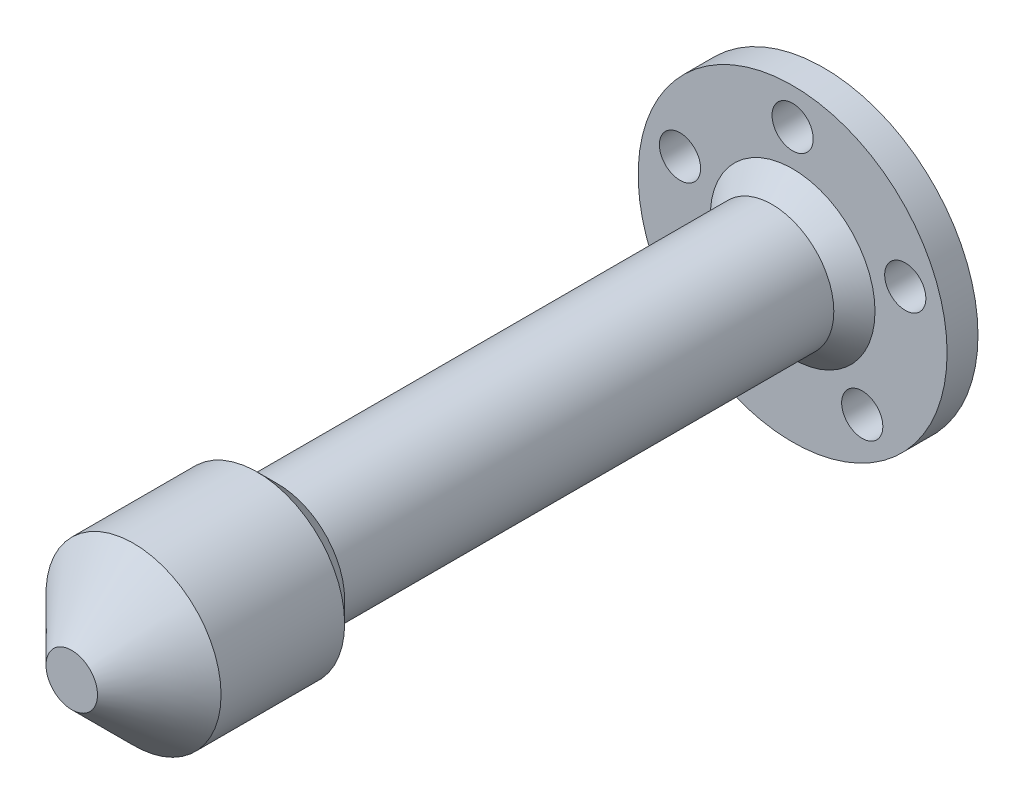
from build123d import *

# Parameters (mm, degrees)
SKETCH1_R           = 15
BOSS_EXTRUDE1_DEPTH = 3
SKETCH2_R           = 2
CUT_EXTRUDE1_DEPTH  = 3
SKETCH3_R           = 6
BOSS_EXTRUDE5_DEPTH = 50
CHAMFER1_SIZE       = 2
SKETCH5_R           = 8.5
BOSS_EXTRUDE6_DEPTH = 20
CHAMFER2_SIZE       = 6
CHAMFER3_SIZE       = 2
SKETCH6_R           = 4.1
CUT_EXTRUDE2_DEPTH  = 60


with BuildPart() as part:
    # Sketch1 → Boss-Extrude1 (new body)
    with BuildSketch(Plane.XY):
        Circle(SKETCH1_R)
    extrude(amount=BOSS_EXTRUDE1_DEPTH)

    # Sketch2 → Cut-Extrude1 (cut)
    with BuildSketch(Plane.XY.offset(3)):
        with Locations((0, 11.5)):
            Circle(SKETCH2_R)
        with Locations((10.937149937, 3.553695435)):
            Circle(SKETCH2_R)
        with Locations((6.759530401, -9.303695435)):
            Circle(SKETCH2_R)
        with Locations((-6.759530401, -9.303695435)):
            Circle(SKETCH2_R)
        with Locations((-10.937149937, 3.553695435)):
            Circle(SKETCH2_R)
    extrude(amount=-CUT_EXTRUDE1_DEPTH, mode=Mode.SUBTRACT)

    # Sketch3 → Boss-Extrude5 (add)
    with BuildSketch(Plane.XY.offset(3)):
        Circle(SKETCH3_R)
    extrude(amount=BOSS_EXTRUDE5_DEPTH)

    # Chamfer1
    chamfer1_edges = [part.edges().sort_by_distance(p)[0] for p in [
        (-6, 0, 3),
    ]]
    chamfer(chamfer1_edges, length=CHAMFER1_SIZE)

    # Sketch5 → Boss-Extrude6 (add)
    with BuildSketch(Plane.XY.offset(53)):
        Circle(SKETCH5_R)
    extrude(amount=BOSS_EXTRUDE6_DEPTH)

    # Chamfer2
    chamfer2_edges = [part.edges().sort_by_distance(p)[0] for p in [
        (-8.5, 0, 73),
    ]]
    chamfer(chamfer2_edges, length=CHAMFER2_SIZE)

    # Chamfer3
    chamfer3_edges = [part.edges().sort_by_distance(p)[0] for p in [
        (-8.5, 0, 53),
    ]]
    chamfer(chamfer3_edges, length=CHAMFER3_SIZE)

    # Sketch6 → Cut-Extrude2 (cut)
    with BuildSketch(Plane(origin=(0, 0, 0), x_dir=(-1, 0, 0), z_dir=(0, 0, -1))):
        Circle(SKETCH6_R)
    extrude(amount=-CUT_EXTRUDE2_DEPTH, mode=Mode.SUBTRACT)


solid = part.part
